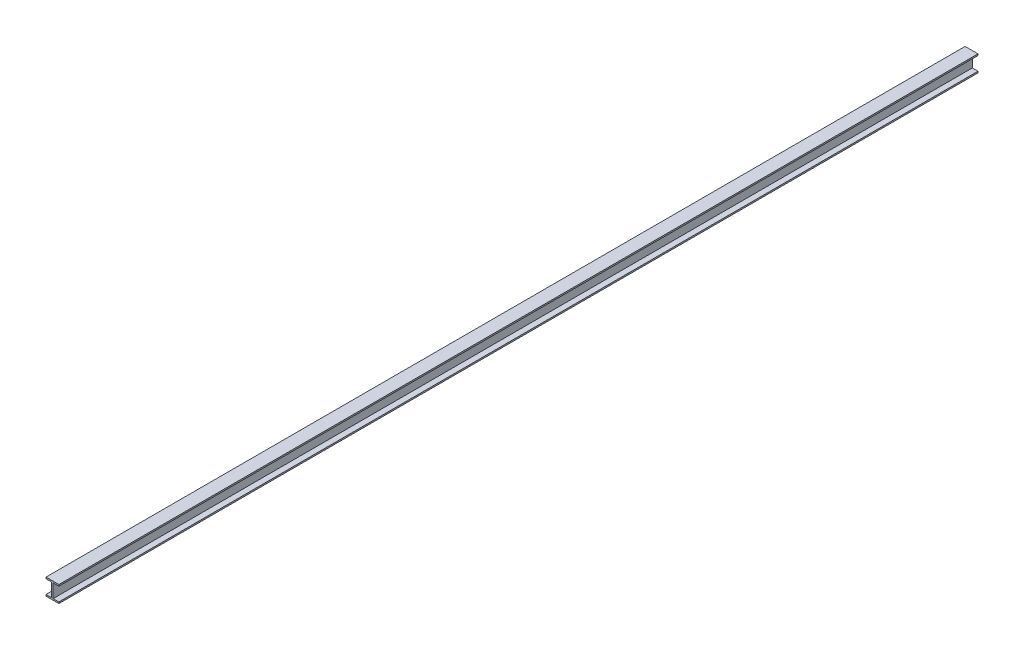
from build123d import *

# Parameters (mm, degrees)
BOSS_EXTRUDE1_DEPTH = 20000


with BuildPart() as part:
    # Sketch1 → Boss-Extrude1 (new body)
    with BuildSketch(Plane.XY):
        Polygon((156, -328), (280, -328), (280, -360), (0, -360), (0, -328), (124, -328), (124, -32), (0, -32), (0, 0), (280, 0), (280, -32), (156, -32), align=None)
    extrude(amount=BOSS_EXTRUDE1_DEPTH)


solid = part.part
